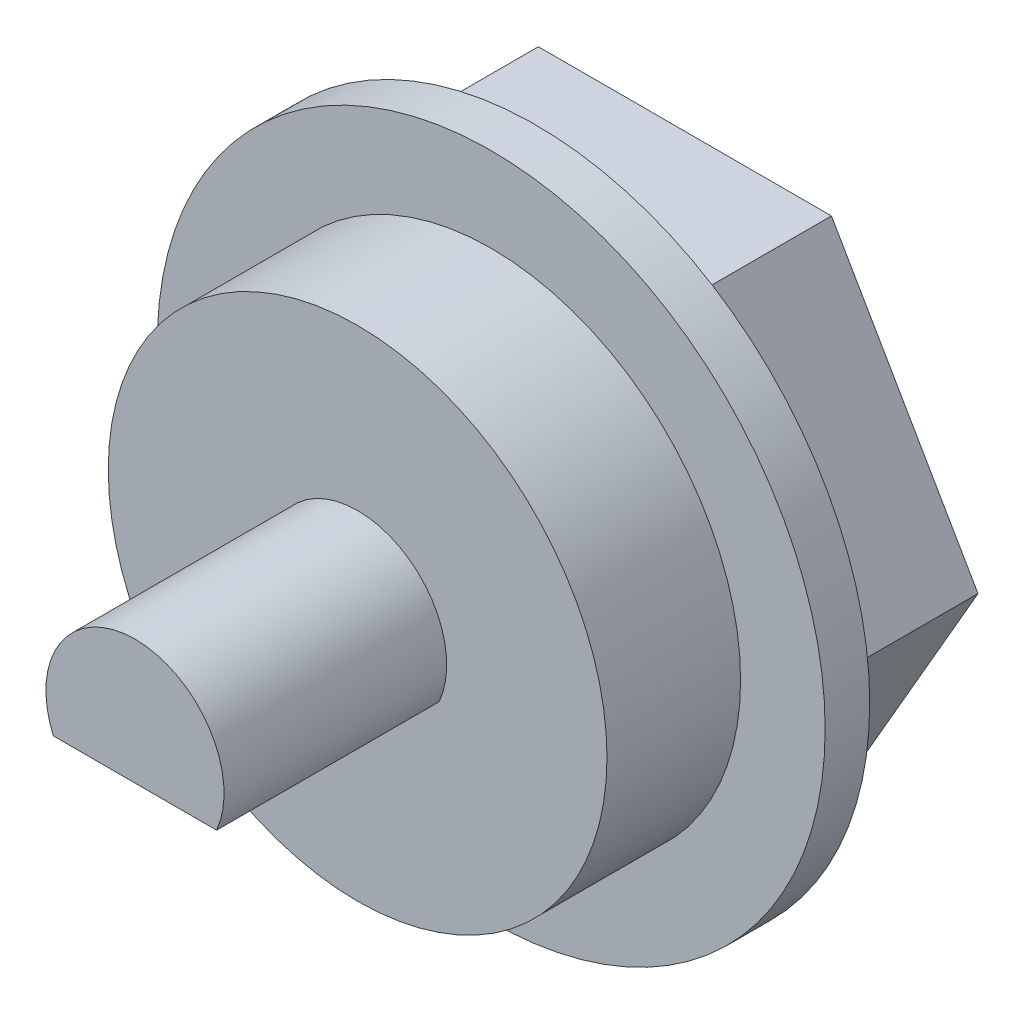
from build123d import *

# Parameters (mm, degrees)
SKETCH1_R           = 7.5
SKETCH1_R_2         = 5.6
BOSS_EXTRUDE1_DEPTH = 1
BOSS_EXTRUDE2_DEPTH = 3.35
BOSS_EXTRUDE3_START = 1
SKETCH1_4_R         = 5.6
BOSS_EXTRUDE3_DEPTH = 3
BOSS_EXTRUDE4_DEPTH = 5


with BuildPart() as part:
    # Sketch1 → Boss-Extrude1 (new body)
    with BuildSketch(Plane.XY):
        Circle(SKETCH1_R)
        Polygon((-3.290896534, 5.7), (-6.581793069, 0), (-3.290896534, -5.7), (3.290896534, -5.7), (6.581793069, 0), (3.290896534, 5.7), align=None, mode=Mode.SUBTRACT)
        Circle(SKETCH1_R)
        Circle(SKETCH1_R_2, mode=Mode.SUBTRACT)
        Circle(SKETCH1_R_2)
    extrude(amount=BOSS_EXTRUDE1_DEPTH)

    # Sketch1_3 → Boss-Extrude2 (add)
    with BuildSketch(Plane.XY):
        Polygon((-3.290896534, -5.7), (3.290896534, -5.7), (6.581793069, 0), (3.290896534, 5.7), (-3.290896534, 5.7), (-6.581793069, 0), align=None)
    extrude(amount=-BOSS_EXTRUDE2_DEPTH)

    # Sketch1_4 → Boss-Extrude3 (add)
    with BuildSketch(Plane.XY.offset(BOSS_EXTRUDE3_START)):
        Circle(SKETCH1_4_R)
    extrude(amount=BOSS_EXTRUDE3_DEPTH)

    # Sketch2 → Boss-Extrude4 (add, symmetric)
    with BuildSketch(Plane.XY.offset(4)):
        with BuildLine():
            Line((-1.833030278, -0.8), (1.833030278, -0.8))
            ThreePointArc((1.833030278, -0.8), (0, 2), (-1.833030278, -0.8))
        make_face()
    extrude(amount=BOSS_EXTRUDE4_DEPTH, both=True)


solid = part.part
